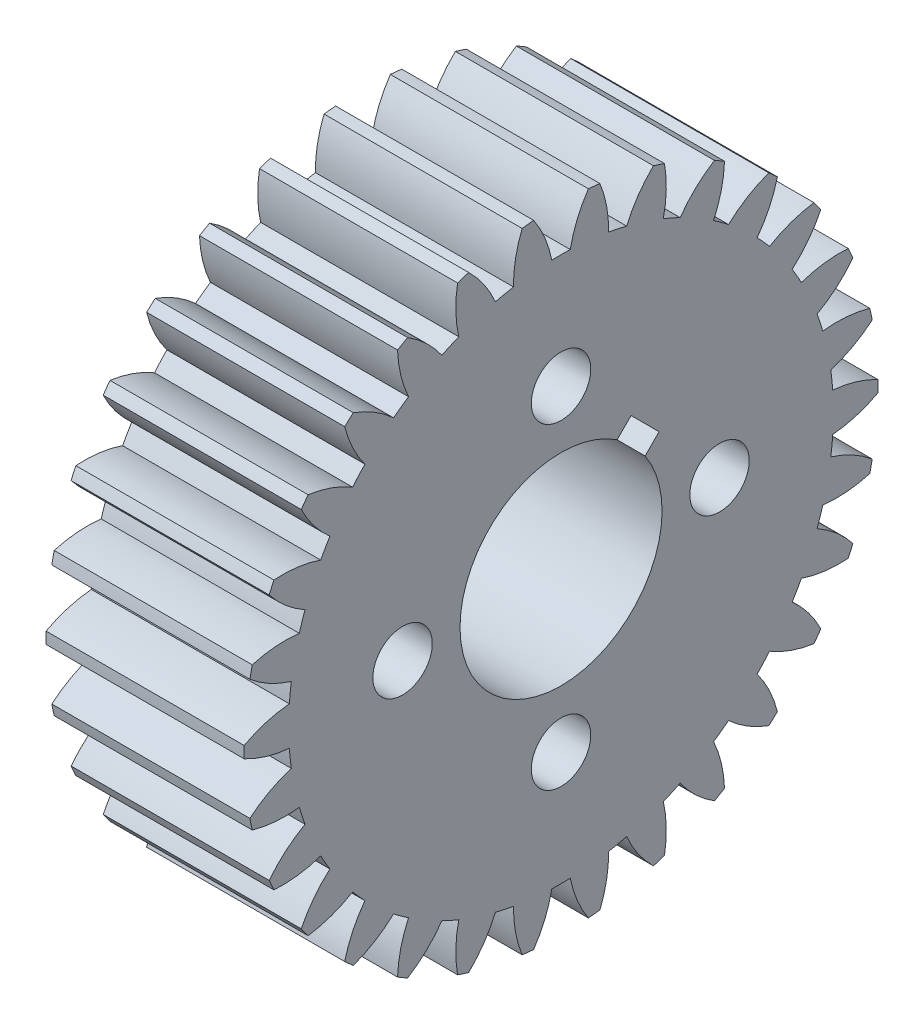
from build123d import *

# Parameters (mm, degrees)
BASPROSKE_W        = 10
BASPROSKE_H        = 16
TOOTHCUT_DEPTH     = 25.738633754
TEETHCUTS_COUNT    = 30
TEETHCUTS_ANGLE    = 348
HUBNEAONESKE_R     = 12.5
HUBNEARONE_DEPTH   = 8.0000508
BORSKE_R           = 3
BORE_DEPTH         = 18.0000508
SKETCH2_R          = 12.5
CUT_EXTRUDE1_DEPTH = 8.0000508
SKETCH3_R          = 5.1
CUT_EXTRUDE2_DEPTH = 10
SKETCH4_R          = 1.5
CUT_EXTRUDE3_DEPTH = 10


with BuildPart() as part:
    # BasProSke → Base-Revolve (revolve)
    with BuildSketch(Plane(origin=(0, 0, 0), x_dir=(1, 0, 0), z_dir=(0, 1, 0)), mode=Mode.PRIVATE) as base_revolve_sk:
        with Locations((5, 8)):
            Rectangle(BASPROSKE_W, BASPROSKE_H)
    revolve(base_revolve_sk.sketch.rotate(Axis((-10, 0, 0), (1, 0, 0)), 180), axis=Axis((-10, 0, 0), (1, 0, 0)))

    # TooCutSke → ToothCut (cut, through all)
    with BuildSketch(Plane(origin=(0, 0, 0), x_dir=(0, 0, -1), z_dir=(1, 0, 0))):
        with BuildLine():
            ThreePointArc((0.466400716, 13.741086979), (0, 13.749), (-0.466400716, 13.741086979))
            ThreePointArc((-0.466400716, 13.741086979), (-0.819142092, 14.899954875), (-1.3974676, 15.964351834))
            ThreePointArc((-1.3974676, 15.964351834), (0, 16.0254), (1.3974676, 15.964351834))
            ThreePointArc((1.3974676, 15.964351834), (0.819142092, 14.899954875), (0.466400716, 13.741086979))
        make_face()
    toothcut = extrude(amount=TOOTHCUT_DEPTH, mode=Mode.SUBTRACT)

    # TeethCuts: ToothCut ×30 about axis
    teethcuts_axis = Axis((-10, 0, 0), (1, 0, 0))
    for i in range(1, TEETHCUTS_COUNT):
        add(toothcut.rotate(teethcuts_axis, i * TEETHCUTS_ANGLE / (TEETHCUTS_COUNT - 1)), mode=Mode.SUBTRACT)

    # HubNeaOneSke → HubNearOne (add)
    with BuildSketch(Plane.ZY):
        with Locations(Location((0, 0, 0), (0, 0, 180))):
            Circle(HUBNEAONESKE_R)
    extrude(amount=HUBNEARONE_DEPTH)

    # BorSke → Bore (cut, symmetric)
    with BuildSketch(Plane(origin=(0, 0, 0), x_dir=(0, 0, -1), z_dir=(1, 0, 0))):
        with Locations(Location((0, 0, 0), (0, 0, 180))):
            Circle(BORSKE_R)
    extrude(amount=BORE_DEPTH, both=True, mode=Mode.SUBTRACT)

    # Sketch2 → Cut-Extrude1 (cut)
    with BuildSketch(Plane.ZY.offset(8.0000508)):
        Circle(SKETCH2_R)
    extrude(amount=-CUT_EXTRUDE1_DEPTH, mode=Mode.SUBTRACT)

    # Sketch3 → Cut-Extrude2 (cut)
    with BuildSketch(Plane(origin=(10, 0, 0), x_dir=(0, 0, -1), z_dir=(1, 0, 0))):
        Circle(SKETCH3_R)
    extrude(amount=-CUT_EXTRUDE2_DEPTH, mode=Mode.SUBTRACT)

    # Sketch4 → Cut-Extrude3 (cut)
    with BuildSketch(Plane.ZY):
        with BuildLine():
            ThreePointArc((-4.243347723, 2.829134161), (-3.606244584, 3.606244584), (-2.829134161, 4.243347723))
            Line((-2.829134161, 4.243347723), (-3.535533906, 4.949747468))
            Line((-3.535533906, 4.949747468), (-4.949747468, 3.535533906))
            Line((-4.949747468, 3.535533906), (-4.243347723, 2.829134161))
        make_face()
        with Locations((0, -8)):
            Circle(SKETCH4_R)
        with Locations((8, 0)):
            Circle(SKETCH4_R)
        with Locations((-8, 0)):
            Circle(SKETCH4_R)
        with Locations((0, 8)):
            Circle(SKETCH4_R)
    extrude(amount=-CUT_EXTRUDE3_DEPTH, mode=Mode.SUBTRACT)


solid = part.part
